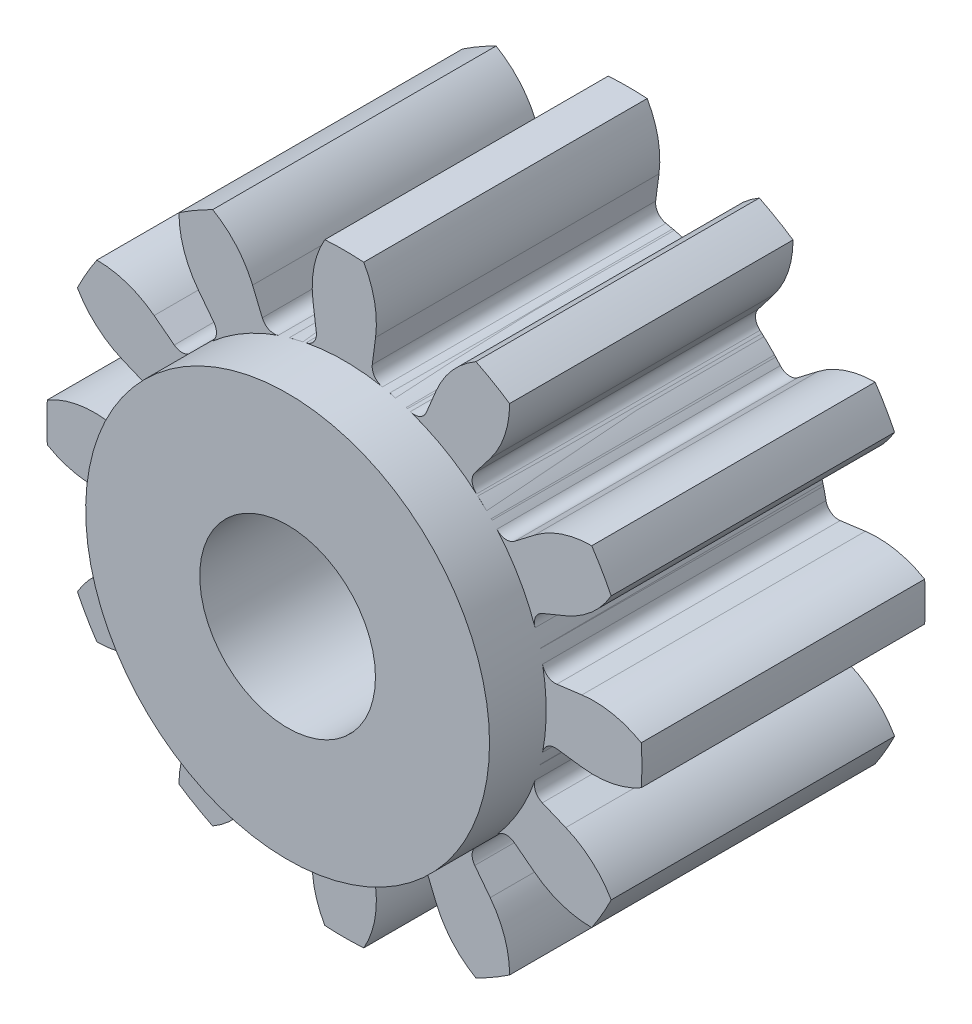
from build123d import *

# Parameters (mm, degrees)
MAINGEAR_DEPTH                     = 10
CONG_1_R                           = 0.45
R_P_TITION_CIRCULAIRE1_COUNT       = 12
CONG_1_OF_R_P_TITION_CIRCULAIRE1_R = 0.45
ESQUISSE5_R                        = 7.125
MAINBASECIRCLE_DEPTH               = 10
ESQUISSE9_R                        = 7.125
ESQUISSE9_R_2                      = 3.1
GEARBOTTOMFIX_DEPTH                = 2
ESQUISSE3_R                        = 3.1
GEARHOLE_DEPTH                     = 13


with BuildPart() as part:
    # Esquisse1 → MainGear (new body)
    with BuildSketch(Plane.XY):
        with BuildLine():
            Line((0, 0), (6.882221512, 1.844085696))
            ThreePointArc((6.882221512, 1.844085696), (6.988095123, 1.390018544), (7.064044637, 0.92999912))
            Line((7.064044637, 0.92999912), (8.384880781, 1.103890497))
            ThreePointArc((8.384880781, 1.103890497), (9.465680859, 1.068283463), (10.477518694, 0.686732857))
            ThreePointArc((10.477518694, 0.686732857), (10.5, 0), (10.477518694, -0.686732857))
            ThreePointArc((10.477518694, -0.686732857), (9.465680859, -1.068283463), (8.384880781, -1.103890497))
            Line((8.384880781, -1.103890497), (7.064044637, -0.92999912))
            ThreePointArc((7.064044637, -0.92999912), (6.988095123, -1.390018544), (6.882221512, -1.844085696))
            Line((6.882221512, -1.844085696), (0, 0))
        make_face()
    maingear = extrude(amount=MAINGEAR_DEPTH)

    # Congé1
    cong_1_edges = [part.edges().sort_by_distance(p)[0] for p in [
        (7.064044637, 0.92999912, 5),
        (7.064044637, -0.92999912, 5),
    ]]
    fillet(cong_1_edges, radius=CONG_1_R)

    # Répétition circulaire1: MainGear ×12 about axis
    r_p_tition_circulaire1_axis = Axis((0, 0, 0), (0, 0, 1))
    for i in range(1, R_P_TITION_CIRCULAIRE1_COUNT):
        add(maingear.rotate(r_p_tition_circulaire1_axis, i * 360 / R_P_TITION_CIRCULAIRE1_COUNT))

    # Congé1 of Répétition circulaire1
    cong_1_of_r_p_tition_circulaire1_edges = [part.edges().sort_by_distance(p)[0] for p in [
        (5.65264255, 4.337425182, 5),
        (6.582641669, 2.726619456, 5),
        (2.726619456, 6.582641669, 5),
        (4.337425182, 5.65264255, 5),
        (-0.92999912, 7.064044637, 5),
        (0.92999912, 7.064044637, 5),
        (-4.337425182, 5.65264255, 5),
        (-2.726619456, 6.582641669, 5),
        (-6.582641669, 2.726619456, 5),
        (-5.65264255, 4.337425182, 5),
        (-7.064044637, -0.92999912, 5),
        (-7.064044637, 0.92999912, 5),
        (-5.65264255, -4.337425182, 5),
        (-6.582641669, -2.726619456, 5),
        (-2.726619456, -6.582641669, 5),
        (-4.337425182, -5.65264255, 5),
        (0.92999912, -7.064044637, 5),
        (-0.92999912, -7.064044637, 5),
        (4.337425182, -5.65264255, 5),
        (2.726619456, -6.582641669, 5),
        (6.582641669, -2.726619456, 5),
        (5.65264255, -4.337425182, 5),
    ]]
    fillet(cong_1_of_r_p_tition_circulaire1_edges, radius=CONG_1_OF_R_P_TITION_CIRCULAIRE1_R)

    # Esquisse9 → GearBottomFix (add)
    with BuildSketch(Plane.XY.offset(10)):
        Circle(ESQUISSE9_R)
        Circle(ESQUISSE9_R_2, mode=Mode.SUBTRACT)
    extrude(amount=GEARBOTTOMFIX_DEPTH)


with BuildPart() as body_2:
    # Esquisse5 → MainBaseCircle (new body, through all)
    with BuildSketch(Plane.XY.offset(10)):
        Circle(ESQUISSE5_R)
    extrude(amount=-MAINBASECIRCLE_DEPTH)


with BuildPart() as gearhole_tool:
    # Esquisse3 → GearHole (new body, through all)
    with BuildSketch(Plane.XY):
        Circle(ESQUISSE3_R)
    extrude(amount=GEARHOLE_DEPTH)


with BuildPart() as part_1:
    add(part.part)

    # GearHole: cut by gearhole_tool
    add(gearhole_tool.part, mode=Mode.SUBTRACT)


with BuildPart() as body_2_1:
    add(body_2.part)

    # GearHole: cut by gearhole_tool
    add(gearhole_tool.part, mode=Mode.SUBTRACT)


solid = Compound([part_1.part, body_2_1.part])
